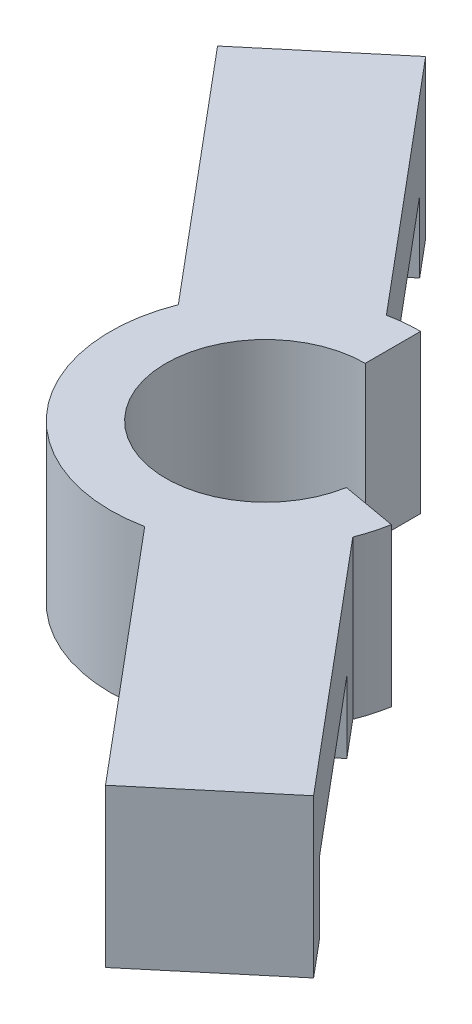
from build123d import *

# Parameters (mm, degrees)
BOSS_EXTRUDE2_DEPTH = 8.55
SKETCH2_W           = 12
SKETCH2_H           = 3.872399236
CUT_EXTRUDE1_DEPTH  = 10


with BuildPart() as part:
    # Sketch1 → Boss-Extrude2 (new body)
    with BuildSketch(Plane(origin=(0, 0, 0), x_dir=(1, 0, 0), z_dir=(0, 1, 0))):
        with BuildLine():
            Line((0, 5.4), (0, 8.4))
            ThreePointArc((0, 8.4), (-0.846182507, 8.357270796), (-1.683756274, 8.229517896))
            Line((-1.683756274, 8.229517896), (-12.757091691, 21.426205161))
            Line((-12.757091691, 21.426205161), (-18.885447236, 16.283904283))
            Line((-18.885447236, 16.283904283), (-7.812111819, 3.087217019))
            ThreePointArc((-7.812111819, 3.087217019), (-6.434773322, -5.399415921), (1.683756274, -8.229517896))
            Line((1.683756274, -8.229517896), (12.757091691, -21.426205161))
            Line((12.757091691, -21.426205161), (18.885447236, -16.283904283))
            Line((18.885447236, -16.283904283), (7.812111819, -3.087217019))
            ThreePointArc((7.812111819, -3.087217019), (8.083367024, -2.284551937), (8.272385125, -1.458644692))
            Line((8.272385125, -1.458644692), (5.317961866, -0.937700159))
            ThreePointArc((5.317961866, -0.937700159), (-4.136639993, -3.471053092), (0, 5.4))
        make_face()
    extrude(amount=BOSS_EXTRUDE2_DEPTH)

    # Sketch2 → Cut-Extrude1 (cut)
    with BuildSketch(Plane(origin=(-3.064177772, 0, 2.571150439), x_dir=(0.64278761, 0, 0.766044443), z_dir=(-0.766044443, 0, 0.64278761))):
        with Locations((-16, 1.936199618)):
            Rectangle(SKETCH2_W, SKETCH2_H)
        with Locations((16, 1.936199618)):
            Rectangle(SKETCH2_W, SKETCH2_H)
    extrude(amount=-CUT_EXTRUDE1_DEPTH, mode=Mode.SUBTRACT)


solid = part.part
